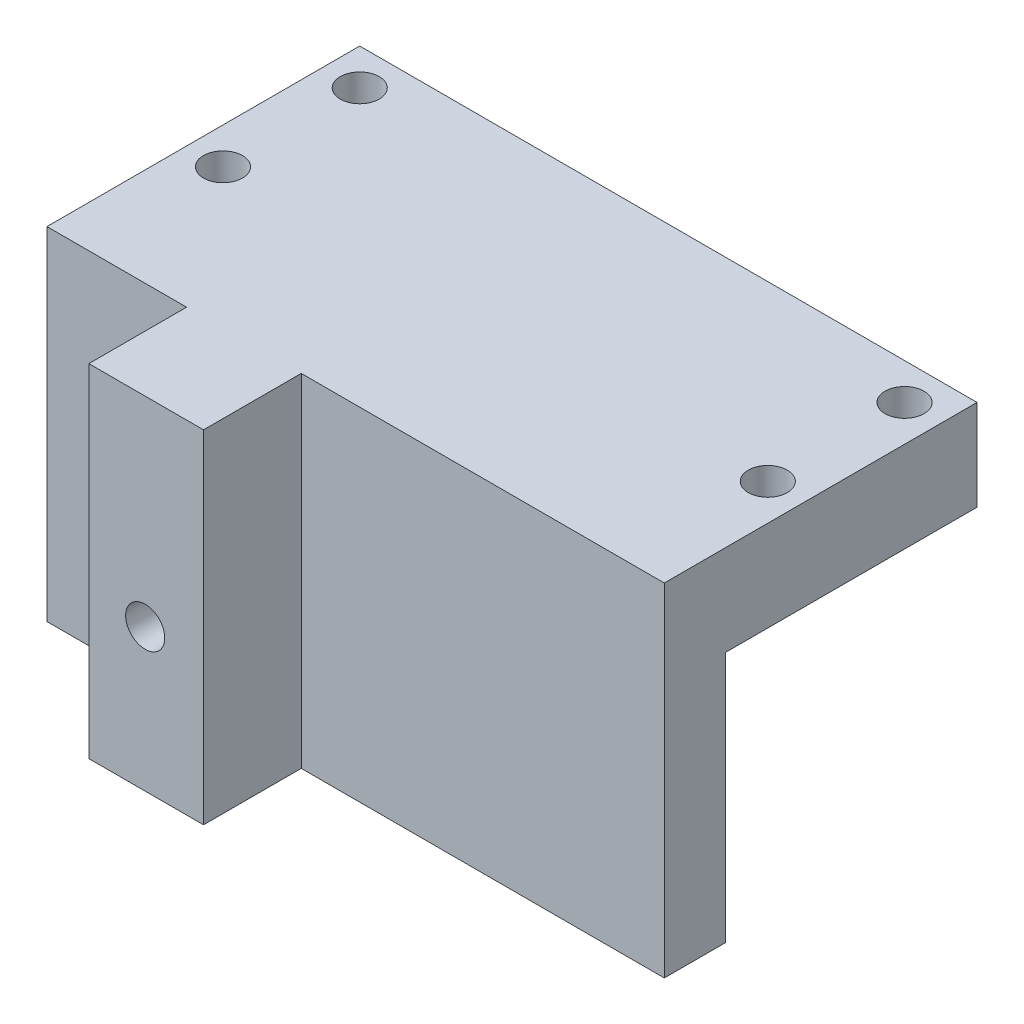
from build123d import *

# Parameters (mm, degrees)
SKETCH1_W           = 56.15
SKETCH1_H           = 25.4
BOSS_EXTRUDE1_DEPTH = 2.54
SKETCH2_W           = 56.15
SKETCH2_H           = 25.4
BOSS_EXTRUDE2_DEPTH = 2.54
SKETCH11_W          = 56.15
SKETCH11_H          = 25.4
BOSS_EXTRUDE3_DEPTH = 5.715
SKETCH6_R           = 1.774
CUT_EXTRUDE3_DEPTH  = 9.255
SKETCH13_W          = 56.15
SKETCH13_H          = 31.115
BOSS_EXTRUDE4_DEPTH = 11.938
SKETCH14_W          = 12.7
SKETCH14_H          = 8.89
SKETCH14_W_2        = 33.02
CUT_EXTRUDE4_DEPTH  = 32.115
SKETCH17_W          = 10.43
SKETCH17_H          = 22.86
BOSS_EXTRUDE5_DEPTH = 14.097
SKETCH15_R          = 1.778
CUT_EXTRUDE5_DEPTH  = 38.338


with BuildPart() as part:
    # Sketch1 → Boss-Extrude1 (new body)
    with BuildSketch(Plane(origin=(0, 0, 0), x_dir=(1, 0, 0), z_dir=(0, 1, 0))):
        with Locations((28.075, 12.7)):
            Rectangle(SKETCH1_W, SKETCH1_H)
    extrude(amount=-BOSS_EXTRUDE1_DEPTH)

    # Sketch2 → Boss-Extrude2 (add)
    with BuildSketch(Plane.XY):
        with Locations((28.075, -12.7)):
            Rectangle(SKETCH2_W, SKETCH2_H)
    extrude(amount=-BOSS_EXTRUDE2_DEPTH)

    # Sketch11 → Boss-Extrude3 (add)
    with BuildSketch(Plane(origin=(0, 0, 0), x_dir=(1, 0, 0), z_dir=(0, 1, 0))):
        with Locations((28.075, 12.7)):
            Rectangle(SKETCH11_W, SKETCH11_H)
    extrude(amount=BOSS_EXTRUDE3_DEPTH)

    # Sketch6 → Cut-Extrude3 (cut, through all)
    with BuildSketch(Plane.XZ.offset(2.54)):
        with Locations((52.852, -22.102)):
            Circle(SKETCH6_R)
        with Locations((52.852, -9.664)):
            Circle(SKETCH6_R)
        with Locations((3.298, -9.664)):
            Circle(SKETCH6_R)
        with Locations((3.298, -22.102)):
            Circle(SKETCH6_R)
    extrude(amount=-CUT_EXTRUDE3_DEPTH, mode=Mode.SUBTRACT)

    # Sketch13 → Boss-Extrude4 (add)
    with BuildSketch(Plane.XY):
        with Locations((28.075, -9.8425)):
            Rectangle(SKETCH13_W, SKETCH13_H)
    extrude(amount=BOSS_EXTRUDE4_DEPTH)

    # Sketch14 → Cut-Extrude4 (cut, through all)
    with BuildSketch(Plane.XZ.offset(25.4)):
        with Locations((6.35, 7.493)):
            Rectangle(SKETCH14_W, SKETCH14_H)
        with Locations((39.64, 7.493)):
            Rectangle(SKETCH14_W_2, SKETCH14_H)
    extrude(amount=-CUT_EXTRUDE4_DEPTH, mode=Mode.SUBTRACT)

    # Sketch17 → Boss-Extrude5 (add)
    with BuildSketch(Plane(origin=(0, 0, -2.54), x_dir=(-1, 0, 0), z_dir=(0, 0, -1))):
        with Locations((-17.915, -13.97)):
            Rectangle(SKETCH17_W, SKETCH17_H)
    extrude(amount=BOSS_EXTRUDE5_DEPTH)

    # Sketch15 → Cut-Extrude5 (cut, through all)
    with BuildSketch(Plane.XY.offset(11.938)):
        with Locations((17.825, -12.45)):
            Circle(SKETCH15_R)
    extrude(amount=-CUT_EXTRUDE5_DEPTH, mode=Mode.SUBTRACT)


solid = part.part
